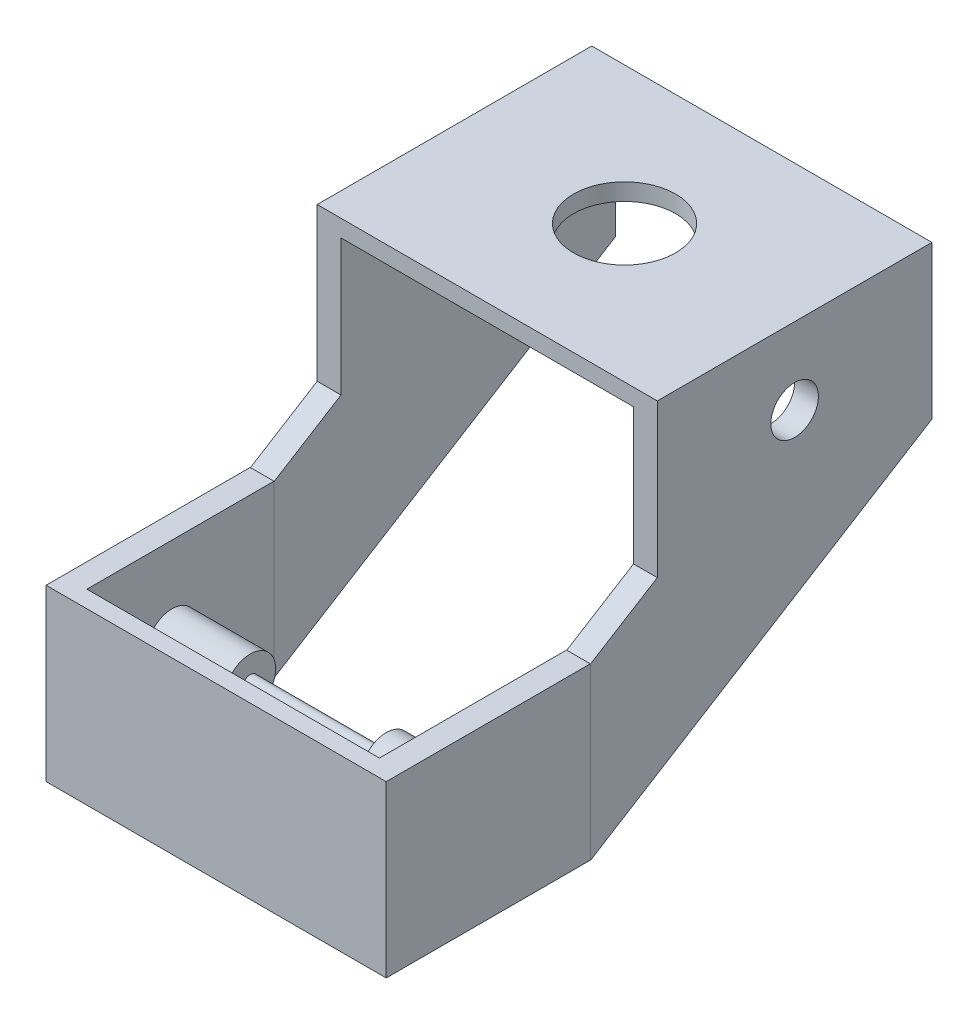
from build123d import *

# Parameters (mm, degrees)
SKETCH1_W            = 100
SKETCH1_H            = 50
BOSS_EXTRUDE1_DEPTH  = 5
SKETCH2_W            = 7
SKETCH2_H            = 50
BOSS_EXTRUDE2_DEPTH  = 55
BOSS_EXTRUDE3_DEPTH  = 7
BOSS_EXTRUDE8_DEPTH  = 7
SKETCH14_W           = 80.726202609
SKETCH14_H           = 40
BOSS_EXTRUDE11_DEPTH = 7
SKETCH15_W           = 80.726202609
SKETCH15_H           = 40
BOSS_EXTRUDE12_DEPTH = 7
SKETCH24_W           = 100
SKETCH24_H           = 80.726202609
BOSS_EXTRUDE21_DEPTH = 5
SKETCH25_R           = 7
CUT_EXTRUDE5_DEPTH   = 101
SKETCH26_R           = 15
CUT_EXTRUDE6_DEPTH   = 5
BOSS_EXTRUDE22_REACH = 102
SKETCH30_R           = 2.25
SKETCH32_R           = 7.5
BOSS_EXTRUDE23_DEPTH = 23
SKETCH33_R           = 7.5
BOSS_EXTRUDE24_DEPTH = 23


with BuildPart() as part:
    # Sketch1 → Boss-Extrude1 (new body)
    with BuildSketch(Plane.XY):
        with Locations((1.428571429, 15.535714286)):
            Rectangle(SKETCH1_W, SKETCH1_H)
    extrude(amount=BOSS_EXTRUDE1_DEPTH)

    # Sketch2 → Boss-Extrude2 (add)
    with BuildSketch(Plane.XY):
        with Locations((47.928571429, 15.535714286)):
            Rectangle(SKETCH2_W, SKETCH2_H)
        with Locations((-45.071428571, 15.535714286)):
            Rectangle(SKETCH2_W, SKETCH2_H)
    extrude(amount=-BOSS_EXTRUDE2_DEPTH)

    # Sketch3 → Boss-Extrude3 (add)
    with BuildSketch(Plane(origin=(44.5, 0, 0), x_dir=(0, 0, -1), z_dir=(1, 0, 0))):
        Polygon((55, 40.535714286), (74.633488262, 52.696256729), (155.359690871, 52.696256729), (55, -9.464285714), align=None)
    extrude(amount=BOSS_EXTRUDE3_DEPTH)

    # Sketch11 → Boss-Extrude8 (add)
    with BuildSketch(Plane.ZY.offset(41.5)):
        Polygon((-55, -9.464285714), (-55, 40.535714286), (-74.633488262, 52.696256729), (-155.359690871, 52.696256729), align=None)
    extrude(amount=BOSS_EXTRUDE8_DEPTH)

    # Sketch14 → Boss-Extrude11 (add)
    with BuildSketch(Plane.ZY.offset(41.5)):
        with Locations((-114.996589567, 72.696256729)):
            Rectangle(SKETCH14_W, SKETCH14_H)
    extrude(amount=BOSS_EXTRUDE11_DEPTH)

    # Sketch15 → Boss-Extrude12 (add)
    with BuildSketch(Plane(origin=(44.5, 0, 0), x_dir=(0, 0, -1), z_dir=(1, 0, 0))):
        with Locations((114.996589567, 72.696256729)):
            Rectangle(SKETCH15_W, SKETCH15_H)
    extrude(amount=BOSS_EXTRUDE12_DEPTH)

    # Sketch24 → Boss-Extrude21 (add)
    with BuildSketch(Plane(origin=(0, 92.696256729, 0), x_dir=(1, 0, 0), z_dir=(0, 1, 0))):
        with Locations((1.5, 114.996589567)):
            Rectangle(SKETCH24_W, SKETCH24_H)
    extrude(amount=BOSS_EXTRUDE21_DEPTH)

    # Sketch25 → Cut-Extrude5 (cut, through all)
    with BuildSketch(Plane.ZY.offset(48.5)):
        with Locations((-114.996589567, 75.196256729)):
            Circle(SKETCH25_R)
    extrude(amount=-CUT_EXTRUDE5_DEPTH, mode=Mode.SUBTRACT)

    # Sketch26 → Cut-Extrude6 (cut)
    with BuildSketch(Plane.XZ.offset(-92.696256729)):
        with Locations((1.5, -114.996589567)):
            Circle(SKETCH26_R)
    extrude(amount=-CUT_EXTRUDE6_DEPTH, mode=Mode.SUBTRACT)

    # Sketch30 → Boss-Extrude22 (add, up to next)
    with BuildSketch(Plane(origin=(51.428571429, 0, 0), x_dir=(0, 0, -1), z_dir=(1, 0, 0)), mode=Mode.PRIVATE) as boss_extrude22_sk1:
        with Locations((25, 15.535714286)):
            Circle(SKETCH30_R)
    boss_extrude22_tool1 = extrude(boss_extrude22_sk1.sketch, amount=-BOSS_EXTRUDE22_REACH, mode=Mode.PRIVATE) - part.part
    add(boss_extrude22_tool1.solids().sort_by_distance((51.428571, 15.535714, -25))[0])

    # Sketch32 → Boss-Extrude23 (add)
    with BuildSketch(Plane.ZY.offset(-44.428571429)):
        with Locations((-25, 15.535714286)):
            Circle(SKETCH32_R)
    extrude(amount=BOSS_EXTRUDE23_DEPTH)

    # Sketch33 → Boss-Extrude24 (add)
    with BuildSketch(Plane(origin=(-41.571428571, 0, 0), x_dir=(0, 0, -1), z_dir=(1, 0, 0))):
        with Locations((25, 15.535714286)):
            Circle(SKETCH33_R)
    extrude(amount=BOSS_EXTRUDE24_DEPTH)


solid = part.part
